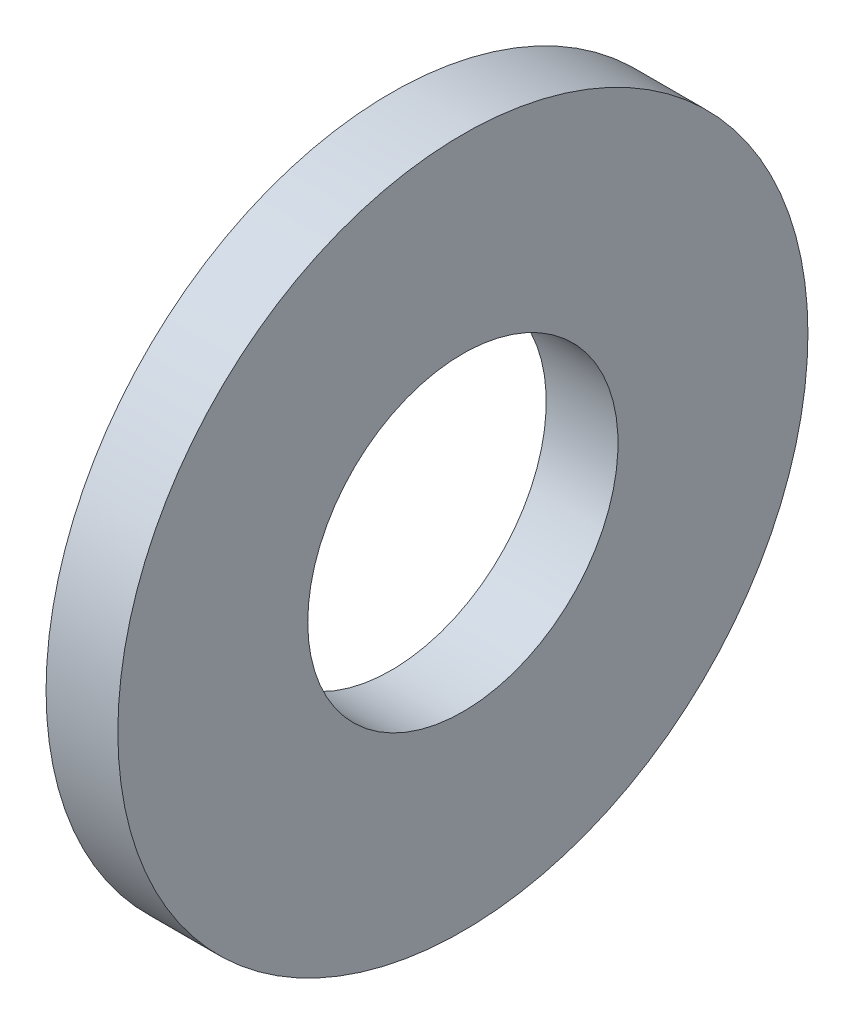
from build123d import *

# Parameters (mm, degrees)
SKETCH1_W = 1.651
SKETCH1_H = 4.3688


with BuildPart() as part:
    # Sketch1 → Base-Revolve (revolve)
    with BuildSketch(Plane.XY):
        with Locations((-0.8255, 5.7531)):
            Rectangle(SKETCH1_W, SKETCH1_H)
    revolve(axis=Axis((-34.925, 0, 0), (1, 0, 0)))


solid = part.part
